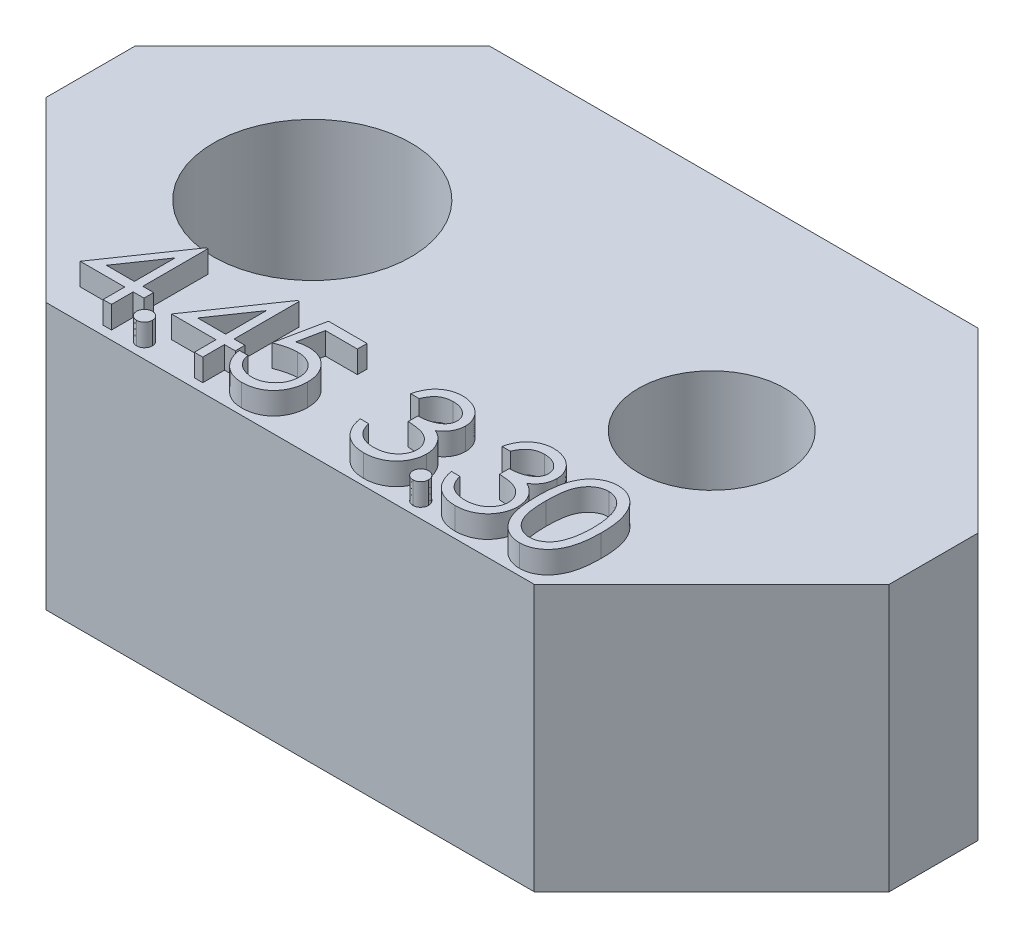
from build123d import *

# Parameters (mm, degrees)
SKETCH_1_R      = 2.225
SKETCH_1_R_2    = 1.65
EXTRUDE_1_DEPTH = 6
SKETCH_1_3_R    = 2.225
SKETCH_1_3_R_2  = 1.65
EXTRUDE_2_DEPTH = 2
EXTRUDE_3_DEPTH = 0.5


with BuildPart() as part:
    # Эскиз1 → Бобышка-Вытянуть1 (new body)
    with BuildSketch(Plane(origin=(0, 0, 0), x_dir=(1, 0, 0), z_dir=(0, 1, 0))):
        Polygon((9.5, 1), (5.5, 5), (-5.5, 5), (-9.5, 1), (-9.5, -1), (-5.5, -5), (5.5, -5), (9.5, -1), align=None)
        with Locations((-4.5, 0)):
            Circle(SKETCH_1_R, mode=Mode.SUBTRACT)
        with Locations((4.5, 0)):
            Circle(SKETCH_1_R_2, mode=Mode.SUBTRACT)
    extrude(amount=EXTRUDE_1_DEPTH)

    # Эскиз1<3> → Бобышка-Вытянуть2 (add)
    with BuildSketch(Plane(origin=(0, 0, 0), x_dir=(1, 0, 0), z_dir=(0, 1, 0))):
        with Locations((-4.5, 0)):
            Circle(SKETCH_1_3_R)
        with Locations((4.5, 0)):
            Circle(SKETCH_1_3_R_2)
    extrude(amount=EXTRUDE_2_DEPTH)

    # Эскиз3 → Бобышка-Вытянуть3 (add)
    # profile 1 of 8: a face of its own
    with BuildSketch(Plane(origin=(0, 6, 0), x_dir=(1, 0, 0), z_dir=(0, 1, 0))):
        Polygon((-4.263157719, -2.629059829), (-4.22457265, -2.629059829), (-4.22457265, -4.094444444), (-3.98034188, -4.094444444), (-3.98034188, -4.311538462), (-4.22457265, -4.311538462), (-4.22457265, -4.8), (-4.414529915, -4.8), (-4.414529915, -4.311538462), (-5.418589744, -4.311538462), align=None)
        Polygon((-4.414529915, -4.094444444), (-4.414529915, -3.175186966), (-5.045459402, -4.094444444), align=None, mode=Mode.SUBTRACT)
    # profile 2 of 8: a face of its own
    with BuildSketch(Plane(origin=(0, 6, 0), x_dir=(1, 0, 0), z_dir=(0, 1, 0))):
        with BuildLine():
            add(Edge.make_bspline(
                [(-3.630277778, -4.474358974), (-3.61849084, -4.475059389), (-3.595383926, -4.476432471), (-3.561977406, -4.48585265), (-3.53174254, -4.502579554), (-3.504811135, -4.524872758), (-3.482612456, -4.551902993), (-3.465289443, -4.581896709), (-3.455951324, -4.61558291), (-3.454588244, -4.638823714), (-3.453888889, -4.650747863)],
                knots=[0, 0, 0, 0, 1.020151414, 1.999887582, 2.974338812, 3.990962822, 5.007586832, 5.987933904, 6.967670073, 8, 8, 8, 8], degree=3))
            add(Edge.make_bspline(
                [(-3.453888889, -4.650747863), (-3.454611943, -4.662385496), (-3.456037794, -4.685334737), (-3.465268038, -4.71876686), (-3.482744478, -4.748779321), (-3.504658021, -4.776176328), (-3.531749198, -4.798516759), (-3.562048886, -4.815101354), (-3.595305504, -4.825196027), (-3.618477757, -4.826481931), (-3.630277778, -4.827136752)],
                knots=[0, 0, 0, 0, 1.009421747, 1.99056486, 2.972319754, 3.999869655, 5.017953583, 5.993804169, 6.978383603, 8, 8, 8, 8], degree=3))
            add(Edge.make_bspline(
                [(-3.630277778, -4.827136752), (-3.642086302, -4.826505624), (-3.665139634, -4.825273498), (-3.698272116, -4.814894086), (-3.72875633, -4.798672279), (-3.755842232, -4.776134672), (-3.777939308, -4.7489203), (-3.794646087, -4.718560166), (-3.804679177, -4.685430439), (-3.80599869, -4.662404346), (-3.806666667, -4.650747863)],
                knots=[0, 0, 0, 0, 1.022052826, 1.995314843, 2.982371812, 4.00089066, 5.028879526, 6.005146991, 6.990147033, 8, 8, 8, 8], degree=3))
            add(Edge.make_bspline(
                [(-3.806666667, -4.650747863), (-3.806024349, -4.638804191), (-3.804770304, -4.615485636), (-3.794625024, -4.582103319), (-3.778068934, -4.551763358), (-3.755689481, -4.524913998), (-3.728762883, -4.502424534), (-3.698345654, -4.486056778), (-3.665059837, -4.476356147), (-3.642072874, -4.475036244), (-3.630277778, -4.474358974)],
                knots=[0, 0, 0, 0, 1.032775665, 2.016367738, 2.991239715, 4.008302682, 5.025365648, 6.011011707, 6.979408107, 8, 8, 8, 8], degree=3))
        make_face()
    # profile 3 of 8: a face of its own
    with BuildSketch(Plane(origin=(0, 6, 0), x_dir=(1, 0, 0), z_dir=(0, 1, 0))):
        Polygon((-2.206191907, -2.629059829), (-2.167606838, -2.629059829), (-2.167606838, -4.094444444), (-1.923376068, -4.094444444), (-1.923376068, -4.311538462), (-2.167606838, -4.311538462), (-2.167606838, -4.8), (-2.357564103, -4.8), (-2.357564103, -4.311538462), (-3.361623932, -4.311538462), align=None)
        Polygon((-2.357564103, -4.094444444), (-2.357564103, -3.175186966), (-2.98849359, -4.094444444), align=None, mode=Mode.SUBTRACT)
    # profile 4 of 8: a face of its own
    with BuildSketch(Plane(origin=(0, 6, 0), x_dir=(1, 0, 0), z_dir=(0, 1, 0))):
        with BuildLine():
            Line((-0.582820513, -2.683333333), (-0.582820513, -2.90042735))
            Line((-0.582820513, -2.90042735), (-1.302792468, -2.90042735))
            Line((-1.302792468, -2.90042735), (-1.416851629, -3.457154781))
            add(Edge.make_bspline(
                [(-1.416851629, -3.457154781), (-1.394441648, -3.450967902), (-1.351025854, -3.438981803), (-1.286945367, -3.425673552), (-1.226111034, -3.417651117), (-1.186634977, -3.416555705), (-1.167532719, -3.416025641)],
                knots=[0, 0, 0, 0, 1.100273476, 2.13160584, 3.095893838, 4, 4, 4, 4], degree=3))
            add(Edge.make_bspline(
                [(-1.167532719, -3.416025641), (-1.143896362, -3.416537231), (-1.097421379, -3.417543144), (-1.029422587, -3.42720231), (-0.964511742, -3.442405973), (-0.902824595, -3.463645526), (-0.844247024, -3.490805222), (-0.789317974, -3.524732329), (-0.737212951, -3.564364391), (-0.688866715, -3.609930184), (-0.645006777, -3.660078019), (-0.606443535, -3.713997303), (-0.573688064, -3.771164032), (-0.547344179, -3.8321244), (-0.526307939, -3.896204459), (-0.512306494, -3.96407845), (-0.502983056, -4.035106598), (-0.501941422, -4.083671743), (-0.501410256, -4.108436832)],
                knots=[0, 0, 0, 0, 1.052922333, 2.070308379, 3.05430497, 4.020497103, 4.973039431, 5.925935799, 6.892292201, 7.88610001, 8.88166317, 9.857072816, 10.836096531, 11.812156883, 12.81219415, 13.836441305, 14.89672472, 16, 16, 16, 16], degree=3))
            add(Edge.make_bspline(
                [(-0.501410256, -4.108436832), (-0.501812469, -4.125685985), (-0.502611457, -4.159951182), (-0.506674603, -4.210838389), (-0.514497632, -4.260648293), (-0.525000969, -4.309387501), (-0.538633765, -4.35696374), (-0.555137145, -4.403513188), (-0.575333791, -4.448746117), (-0.597487051, -4.493090523), (-0.622431349, -4.535543906), (-0.650116447, -4.575245912), (-0.679366053, -4.61279212), (-0.710838701, -4.647779854), (-0.744826922, -4.679979203), (-0.780919092, -4.709581259), (-0.818827213, -4.737086635), (-0.859137764, -4.761378829), (-0.900952504, -4.783732617), (-0.944875283, -4.802071137), (-0.989906278, -4.818466552), (-1.036693607, -4.831535171), (-1.085131294, -4.841775335), (-1.135299182, -4.84873046), (-1.186934158, -4.85379621), (-1.221934761, -4.854113321), (-1.239614717, -4.854273504)],
                knots=[0, 0, 0, 0, 1.056347294, 2.098418968, 3.122841568, 4.141288669, 5.149314143, 6.15115421, 7.162517403, 8.180376062, 9.185164535, 10.17417709, 11.141909838, 12.097768115, 13.052685741, 14.0056014, 14.954263652, 15.917497458, 16.885230207, 17.854509472, 18.828990115, 19.81800267, 20.826176721, 21.857883937, 22.917946725, 24, 24, 24, 24], degree=3))
            add(Edge.make_bspline(
                [(-1.239614717, -4.854273504), (-1.260705293, -4.853855712), (-1.302198509, -4.853033754), (-1.362989519, -4.844434956), (-1.421478828, -4.832119635), (-1.477195604, -4.813591986), (-1.530639177, -4.790376813), (-1.581090059, -4.761036081), (-1.629837362, -4.727786813), (-1.674899403, -4.688549647), (-1.716722386, -4.645662544), (-1.754161084, -4.599121495), (-1.787503771, -4.549694642), (-1.816216504, -4.497141948), (-1.840708164, -4.441601504), (-1.859948657, -4.382865213), (-1.875477948, -4.321239972), (-1.882047731, -4.278813801), (-1.885384615, -4.257264957)],
                knots=[0, 0, 0, 0, 1.0467383, 2.05933395, 3.04377827, 4.011590433, 4.970194871, 5.932262533, 6.905835911, 7.896367577, 8.894135286, 9.877477877, 10.858688626, 11.851381753, 12.8477658, 13.868841284, 14.917554742, 16, 16, 16, 16], degree=3))
            Line((-1.885384615, -4.257264957), (-1.69542735, -4.257264957))
            add(Edge.make_bspline(
                [(-1.69542735, -4.257264957), (-1.690753413, -4.277449764), (-1.681769847, -4.316246084), (-1.662051132, -4.370754086), (-1.637941769, -4.419328092), (-1.609273425, -4.46261065), (-1.575074121, -4.500353234), (-1.536049181, -4.533988314), (-1.492296034, -4.564332321), (-1.443677271, -4.589625137), (-1.392385552, -4.611196241), (-1.338702525, -4.625560361), (-1.284089896, -4.635660425), (-1.247152025, -4.636671442), (-1.228590411, -4.637179487)],
                knots=[0, 0, 0, 0, 1.136247022, 2.183929868, 3.172523383, 4.106158343, 5.02341133, 5.958108904, 6.928429099, 7.938127109, 8.96079061, 9.975095812, 10.982467395, 12, 12, 12, 12], degree=3))
            add(Edge.make_bspline(
                [(-1.228590411, -4.637179487), (-1.210472685, -4.636683112), (-1.174798735, -4.635705745), (-1.122298515, -4.628183104), (-1.071611682, -4.616597335), (-1.023238376, -4.599258899), (-0.976332111, -4.578186141), (-0.932079402, -4.551144166), (-0.889200043, -4.520023108), (-0.849026839, -4.484368384), (-0.812233458, -4.445077187), (-0.779723803, -4.403059907), (-0.752644432, -4.358236861), (-0.72982428, -4.31138405), (-0.712495857, -4.26198797), (-0.70013393, -4.210280116), (-0.692874937, -4.156132771), (-0.691876367, -4.119200379), (-0.691367521, -4.100380609)],
                knots=[0, 0, 0, 0, 1.027316725, 2.022795036, 3.002884548, 3.971462791, 4.93288096, 5.914575861, 6.907176829, 7.935150275, 8.956128384, 9.956726525, 10.942570165, 11.921478529, 12.907843606, 13.90538589, 14.932640048, 16, 16, 16, 16], degree=3))
            add(Edge.make_bspline(
                [(-0.691367521, -4.100380609), (-0.691765745, -4.083401464), (-0.69254521, -4.050167203), (-0.698913698, -4.001544826), (-0.709991105, -3.955538748), (-0.725366499, -3.911926807), (-0.744887916, -3.870667868), (-0.768743543, -3.83171935), (-0.797381074, -3.795594604), (-0.830093787, -3.762276726), (-0.865930793, -3.731527683), (-0.905508675, -3.70531483), (-0.947999203, -3.683262842), (-0.992890437, -3.664232195), (-1.041250161, -3.650564126), (-1.092120696, -3.640302595), (-1.146051371, -3.634366637), (-1.182924121, -3.633543019), (-1.201877671, -3.633119658)],
                knots=[0, 0, 0, 0, 1.045622112, 2.046656509, 3.013763289, 3.955457236, 4.890082067, 5.820317437, 6.762574623, 7.722996705, 8.69280354, 9.665887285, 10.63943826, 11.638615906, 12.663482002, 13.728887084, 14.832589034, 16, 16, 16, 16], degree=3))
            add(Edge.make_bspline(
                [(-1.201877671, -3.633119658), (-1.218284214, -3.633470778), (-1.252159562, -3.63419575), (-1.304122414, -3.639533679), (-1.358727409, -3.648145062), (-1.415765223, -3.659990078), (-1.475407149, -3.675490777), (-1.537527325, -3.694065737), (-1.602256362, -3.716273803), (-1.645870414, -3.733045189), (-1.668290598, -3.741666667)],
                knots=[0, 0, 0, 0, 0.817624296, 1.688186739, 2.600797293, 3.572016777, 4.590301741, 5.671205678, 6.80286297, 8, 8, 8, 8], degree=3))
            Line((-1.668290598, -3.741666667), (-1.451196581, -2.683333333))
            Line((-1.451196581, -2.683333333), (-0.582820513, -2.683333333))
        make_face()
    # profile 5 of 8: a face of its own
    with BuildSketch(Plane(origin=(0, 6, 0), x_dir=(1, 0, 0), z_dir=(0, 1, 0))):
        with BuildLine():
            Line((1.077948718, -3.171794872), (0.887991453, -3.171794872))
            add(Edge.make_bspline(
                [(0.887991453, -3.171794872), (0.893137705, -3.150487608), (0.903198207, -3.108833649), (0.924181978, -3.049320687), (0.947041527, -2.993003128), (0.974491128, -2.940935503), (1.004432137, -2.892071405), (1.038735878, -2.847519125), (1.07581971, -2.806145569), (1.116837656, -2.769428516), (1.159853561, -2.73618008), (1.205473545, -2.707831831), (1.252779771, -2.683445319), (1.302099999, -2.663354989), (1.353581065, -2.648220505), (1.406757551, -2.637239961), (1.461768811, -2.630109144), (1.499111402, -2.629413207), (1.518072917, -2.629059829)],
                knots=[0, 0, 0, 0, 1.162005537, 2.271625781, 3.343758855, 4.383309926, 5.390229558, 6.379919256, 7.361854164, 8.333198761, 9.295911338, 10.242430842, 11.177959212, 12.116337295, 13.062827104, 14.020064771, 14.994644689, 16, 16, 16, 16], degree=3))
            add(Edge.make_bspline(
                [(1.518072917, -2.629059829), (1.545700099, -2.629893935), (1.600351834, -2.631543953), (1.680641867, -2.646611255), (1.75806761, -2.670454073), (1.831781584, -2.703397708), (1.900251779, -2.744030035), (1.961173187, -2.792389662), (2.013720048, -2.847543525), (2.057803791, -2.908462743), (2.092320576, -2.973568693), (2.117772811, -3.040576408), (2.133267828, -3.109326933), (2.135275974, -3.155746811), (2.136282051, -3.179003072)],
                knots=[0, 0, 0, 0, 1.083050992, 2.142477498, 3.193116406, 4.255571735, 5.30263384, 6.308962982, 7.297363603, 8.282367274, 9.249857812, 10.179914175, 11.08814088, 12, 12, 12, 12], degree=3))
            add(Edge.make_bspline(
                [(2.136282051, -3.179003072), (2.135578356, -3.201383371), (2.134201333, -3.245178145), (2.122509044, -3.309114479), (2.102832352, -3.369373923), (2.075575876, -3.426210149), (2.040293129, -3.47926279), (1.997552975, -3.52865121), (1.947053746, -3.574594463), (1.908785055, -3.600913382), (1.8890832, -3.614463141)],
                knots=[0, 0, 0, 0, 1.024540389, 2.004866551, 2.965041327, 3.920577974, 4.882998113, 5.874504559, 6.905732034, 8, 8, 8, 8], degree=3))
            add(Edge.make_bspline(
                [(1.8890832, -3.614463141), (1.911599547, -3.625335654), (1.956210942, -3.646877248), (2.017020072, -3.689123349), (2.072221454, -3.737901235), (2.103006084, -3.775966554), (2.118473558, -3.795092147)],
                knots=[0, 0, 0, 0, 1.015518401, 2.012035669, 3.001164323, 4, 4, 4, 4], degree=3))
            add(Edge.make_bspline(
                [(2.118473558, -3.795092147), (2.12865856, -3.809036597), (2.148861778, -3.836697147), (2.173799458, -3.881169176), (2.196423065, -3.926134124), (2.214052007, -3.972797193), (2.227703822, -4.02061754), (2.23746228, -4.069677275), (2.243524498, -4.12001646), (2.244392665, -4.154072102), (2.24482906, -4.171190572)],
                knots=[0, 0, 0, 0, 1.025084078, 2.033381695, 3.024893161, 4.013698104, 4.991890475, 5.976764909, 6.982997093, 8, 8, 8, 8], degree=3))
            add(Edge.make_bspline(
                [(2.24482906, -4.171190572), (2.243743806, -4.200829784), (2.241578407, -4.259968726), (2.222223562, -4.347341534), (2.192219364, -4.432749338), (2.149609693, -4.514437455), (2.097680295, -4.590867495), (2.035899437, -4.659251739), (1.964969085, -4.718033752), (1.885862812, -4.767146604), (1.800157691, -4.80640649), (1.708490548, -4.833655515), (1.612182182, -4.851402858), (1.546137768, -4.853305964), (1.512560764, -4.854273504)],
                knots=[0, 0, 0, 0, 0.955779014, 1.907060117, 2.875433937, 3.871313158, 4.872415639, 5.851225146, 6.836215519, 7.83643374, 8.849228613, 9.86973379, 10.916971861, 12, 12, 12, 12], degree=3))
            add(Edge.make_bspline(
                [(1.512560764, -4.854273504), (1.489930997, -4.853748442), (1.445403161, -4.852715294), (1.379941616, -4.845652521), (1.317456589, -4.832752947), (1.257863594, -4.815394281), (1.201109691, -4.793385942), (1.147368065, -4.76597892), (1.096308082, -4.733738154), (1.048411574, -4.69628308), (1.003684249, -4.654384365), (0.963314745, -4.607298201), (0.926630013, -4.55589501), (0.894612322, -4.499577733), (0.865803307, -4.439074172), (0.842108157, -4.373609604), (0.821252599, -4.303769267), (0.811556171, -4.255099396), (0.806581197, -4.230128205)],
                knots=[0, 0, 0, 0, 1.048658725, 2.063410685, 3.046034179, 4.001477787, 4.936774919, 5.862367409, 6.792675028, 7.730719943, 8.675894397, 9.627829632, 10.600096036, 11.597688215, 12.626045268, 13.701542398, 14.82072376, 16, 16, 16, 16], degree=3))
            Line((0.806581197, -4.230128205), (0.996538462, -4.230128205))
            add(Edge.make_bspline(
                [(0.996538462, -4.230128205), (1.001487404, -4.246425942), (1.011113528, -4.278126455), (1.027499128, -4.323749878), (1.046167083, -4.365574034), (1.066193506, -4.403905732), (1.087226185, -4.43912247), (1.11076045, -4.470293029), (1.135053218, -4.498786509), (1.153365018, -4.514839679), (1.162327057, -4.522696314)],
                knots=[0, 0, 0, 0, 1.198163088, 2.33053128, 3.407730985, 4.417276592, 5.372219308, 6.28897303, 7.162600585, 8, 8, 8, 8], degree=3))
            add(Edge.make_bspline(
                [(1.162327057, -4.522696314), (1.17417832, -4.531833259), (1.197844263, -4.550078945), (1.23640886, -4.573363263), (1.276967148, -4.59353874), (1.320397928, -4.608950309), (1.365764003, -4.621999656), (1.413798648, -4.630539208), (1.464078079, -4.636398245), (1.49840906, -4.636915275), (1.515952858, -4.637179487)],
                knots=[0, 0, 0, 0, 0.946170439, 1.889420265, 2.845303464, 3.807233317, 4.801018734, 5.828864929, 6.890507805, 8, 8, 8, 8], degree=3))
            add(Edge.make_bspline(
                [(1.515952858, -4.637179487), (1.535760929, -4.636807011), (1.574493901, -4.636078666), (1.631011839, -4.629380501), (1.684779677, -4.619625441), (1.735200446, -4.604559018), (1.78293461, -4.585943932), (1.827313036, -4.562570849), (1.868918301, -4.535148088), (1.907217512, -4.503979169), (1.941655986, -4.469857598), (1.971978454, -4.434168741), (1.997756225, -4.397063072), (2.018550103, -4.358335256), (2.034969722, -4.318145666), (2.046147657, -4.276381516), (2.053919764, -4.233384598), (2.054552715, -4.204157079), (2.054871795, -4.189423077)],
                knots=[0, 0, 0, 0, 1.217147791, 2.380027433, 3.494444702, 4.572153297, 5.609568379, 6.639424714, 7.649109417, 8.668170816, 9.669597737, 10.625200337, 11.543417969, 12.441394052, 13.322311151, 14.205496177, 15.095365482, 16, 16, 16, 16], degree=3))
            add(Edge.make_bspline(
                [(2.054871795, -4.189423077), (2.053946327, -4.169700982), (2.052099996, -4.130354925), (2.038003855, -4.072468583), (2.01481797, -4.016695376), (1.98235888, -3.963986874), (1.94284632, -3.915136686), (1.896663734, -3.871550599), (1.843427615, -3.835585354), (1.794429884, -3.8107365), (1.751029052, -3.793780745), (1.713887367, -3.782486838), (1.672305992, -3.772923341), (1.626787772, -3.76402592), (1.576989731, -3.756453485), (1.522966086, -3.750138673), (1.464705887, -3.745085862), (1.42437361, -3.742829438), (1.403589744, -3.741666667)],
                knots=[0, 0, 0, 0, 1.07054697, 2.135767047, 3.216561865, 4.33974944, 5.486079747, 6.621378074, 7.775625952, 8.963672916, 9.598146892, 10.304877434, 11.070270905, 11.915000392, 12.823868403, 13.805723172, 14.86925407, 16, 16, 16, 16], degree=3))
            Line((1.403589744, -3.741666667), (1.403589744, -3.52457265))
            add(Edge.make_bspline(
                [(1.403589744, -3.52457265), (1.429776639, -3.524128268), (1.481070334, -3.523257834), (1.55599689, -3.512730133), (1.627645036, -3.498167086), (1.694426923, -3.475860327), (1.75529543, -3.449952148), (1.808102999, -3.419803431), (1.852109798, -3.386290701), (1.88710197, -3.348896695), (1.913426789, -3.30879188), (1.932674424, -3.266992759), (1.944044145, -3.223132969), (1.945561896, -3.19320048), (1.946324786, -3.178155048)],
                knots=[0, 0, 0, 0, 1.321986639, 2.589447074, 3.816329219, 5.01088745, 6.139805852, 7.153945165, 8.075214402, 8.924034688, 9.728124013, 10.488707548, 11.240355623, 12, 12, 12, 12], degree=3))
            add(Edge.make_bspline(
                [(1.946324786, -3.178155048), (1.946074166, -3.167101364), (1.94557557, -3.145110584), (1.939287692, -3.112982566), (1.929838868, -3.081836756), (1.916848746, -3.051805604), (1.899461721, -3.023097391), (1.878654291, -2.995467362), (1.853878344, -2.969073267), (1.825487526, -2.94447136), (1.795000387, -2.921025202), (1.761587428, -2.901120288), (1.726256104, -2.884099227), (1.688967298, -2.870063004), (1.649600001, -2.859504292), (1.608339178, -2.851923093), (1.565106151, -2.847183178), (1.535610865, -2.846500755), (1.520616987, -2.846153846)],
                knots=[0, 0, 0, 0, 0.884392785, 1.759457502, 2.611959086, 3.489218968, 4.37281399, 5.2945488, 6.255912374, 7.266815255, 8.301784654, 9.332968512, 10.37626691, 11.440494194, 12.520033166, 13.637162961, 14.798855837, 16, 16, 16, 16], degree=3))
            add(Edge.make_bspline(
                [(1.520616987, -2.846153846), (1.496516217, -2.846995289), (1.449441806, -2.848638822), (1.381578499, -2.863033978), (1.31849014, -2.886001676), (1.270267232, -2.913417359), (1.234657294, -2.940480717), (1.209210765, -2.964116255), (1.184221695, -2.990382773), (1.161334071, -3.020898076), (1.138187428, -3.053595611), (1.117114765, -3.090137551), (1.096637713, -3.129570685), (1.084299028, -3.157447569), (1.077948718, -3.171794872)],
                knots=[0, 0, 0, 0, 1.472543308, 2.876219568, 4.221790263, 5.565193594, 6.249813518, 6.953379497, 7.687249741, 8.463570142, 9.283606569, 10.136032583, 11.040678096, 12, 12, 12, 12], degree=3))
        make_face()
    # profile 6 of 8: a face of its own
    with BuildSketch(Plane(origin=(0, 6, 0), x_dir=(1, 0, 0), z_dir=(0, 1, 0))):
        with BuildLine():
            add(Edge.make_bspline(
                [(2.594893162, -4.474358974), (2.6066801, -4.475059389), (2.629787014, -4.476432471), (2.663193534, -4.48585265), (2.6934284, -4.502579554), (2.720359805, -4.524872758), (2.742558484, -4.551902993), (2.759881497, -4.581896709), (2.769219616, -4.61558291), (2.770582696, -4.638823714), (2.771282051, -4.650747863)],
                knots=[0, 0, 0, 0, 1.020151414, 1.999887582, 2.974338812, 3.990962822, 5.007586832, 5.987933904, 6.967670073, 8, 8, 8, 8], degree=3))
            add(Edge.make_bspline(
                [(2.771282051, -4.650747863), (2.770558997, -4.662385496), (2.769133146, -4.685334737), (2.759902902, -4.71876686), (2.742426462, -4.748779321), (2.720512919, -4.776176328), (2.693421742, -4.798516759), (2.663122054, -4.815101354), (2.629865436, -4.825196027), (2.606693184, -4.826481931), (2.594893162, -4.827136752)],
                knots=[0, 0, 0, 0, 1.009421747, 1.99056486, 2.972319754, 3.999869655, 5.017953583, 5.993804169, 6.978383603, 8, 8, 8, 8], degree=3))
            add(Edge.make_bspline(
                [(2.594893162, -4.827136752), (2.583084638, -4.826505624), (2.560031307, -4.825273498), (2.526898824, -4.814894086), (2.49641461, -4.798672279), (2.469328708, -4.776134672), (2.447231633, -4.7489203), (2.430524853, -4.718560166), (2.420491763, -4.685430439), (2.41917225, -4.662404346), (2.418504274, -4.650747863)],
                knots=[0, 0, 0, 0, 1.022052826, 1.995314843, 2.982371812, 4.00089066, 5.028879526, 6.005146991, 6.990147033, 8, 8, 8, 8], degree=3))
            add(Edge.make_bspline(
                [(2.418504274, -4.650747863), (2.419146591, -4.638804191), (2.420400636, -4.615485636), (2.430545916, -4.582103319), (2.447102006, -4.551763358), (2.46948146, -4.524913998), (2.496408058, -4.502424534), (2.526825286, -4.486056778), (2.560111104, -4.476356147), (2.583098066, -4.475036244), (2.594893162, -4.474358974)],
                knots=[0, 0, 0, 0, 1.032775665, 2.016367738, 2.991239715, 4.008302682, 5.025365648, 6.011011707, 6.979408107, 8, 8, 8, 8], degree=3))
        make_face()
    # profile 7 of 8: a face of its own
    with BuildSketch(Plane(origin=(0, 6, 0), x_dir=(1, 0, 0), z_dir=(0, 1, 0))):
        with BuildLine():
            Line((3.13491453, -3.171794872), (2.944957265, -3.171794872))
            add(Edge.make_bspline(
                [(2.944957265, -3.171794872), (2.950103517, -3.150487608), (2.960164019, -3.108833649), (2.98114779, -3.049320687), (3.004007339, -2.993003128), (3.03145694, -2.940935503), (3.061397949, -2.892071405), (3.09570169, -2.847519125), (3.132785522, -2.806145569), (3.173803468, -2.769428516), (3.216819373, -2.73618008), (3.262439357, -2.707831831), (3.309745583, -2.683445319), (3.359065811, -2.663354989), (3.410546877, -2.648220505), (3.463723363, -2.637239961), (3.518734623, -2.630109144), (3.556077214, -2.629413207), (3.575038729, -2.629059829)],
                knots=[0, 0, 0, 0, 1.162005537, 2.271625781, 3.343758855, 4.383309926, 5.390229558, 6.379919256, 7.361854164, 8.333198761, 9.295911338, 10.242430842, 11.177959212, 12.116337295, 13.062827104, 14.020064771, 14.994644689, 16, 16, 16, 16], degree=3))
            add(Edge.make_bspline(
                [(3.575038729, -2.629059829), (3.602665911, -2.629893935), (3.657317646, -2.631543953), (3.737607679, -2.646611255), (3.815033422, -2.670454073), (3.888747396, -2.703397708), (3.957217591, -2.744030035), (4.018138999, -2.792389662), (4.07068586, -2.847543525), (4.114769603, -2.908462743), (4.149286388, -2.973568693), (4.174738623, -3.040576408), (4.19023364, -3.109326933), (4.192241786, -3.155746811), (4.193247863, -3.179003072)],
                knots=[0, 0, 0, 0, 1.083050992, 2.142477498, 3.193116406, 4.255571735, 5.30263384, 6.308962982, 7.297363603, 8.282367274, 9.249857812, 10.179914175, 11.08814088, 12, 12, 12, 12], degree=3))
            add(Edge.make_bspline(
                [(4.193247863, -3.179003072), (4.192544168, -3.201383371), (4.191167145, -3.245178145), (4.179474856, -3.309114479), (4.159798164, -3.369373923), (4.132541688, -3.426210149), (4.097258941, -3.47926279), (4.054518787, -3.52865121), (4.004019558, -3.574594463), (3.965750867, -3.600913382), (3.946049012, -3.614463141)],
                knots=[0, 0, 0, 0, 1.024540389, 2.004866551, 2.965041327, 3.920577974, 4.882998113, 5.874504559, 6.905732034, 8, 8, 8, 8], degree=3))
            add(Edge.make_bspline(
                [(3.946049012, -3.614463141), (3.968565359, -3.625335654), (4.013176754, -3.646877248), (4.073985884, -3.689123349), (4.129187265, -3.737901235), (4.159971896, -3.775966554), (4.17543937, -3.795092147)],
                knots=[0, 0, 0, 0, 1.015518401, 2.012035669, 3.001164323, 4, 4, 4, 4], degree=3))
            add(Edge.make_bspline(
                [(4.17543937, -3.795092147), (4.185624372, -3.809036597), (4.20582759, -3.836697147), (4.23076527, -3.881169176), (4.253388877, -3.926134124), (4.271017819, -3.972797193), (4.284669634, -4.02061754), (4.294428092, -4.069677275), (4.30049031, -4.12001646), (4.301358477, -4.154072102), (4.301794872, -4.171190572)],
                knots=[0, 0, 0, 0, 1.025084078, 2.033381695, 3.024893161, 4.013698104, 4.991890475, 5.976764909, 6.982997093, 8, 8, 8, 8], degree=3))
            add(Edge.make_bspline(
                [(4.301794872, -4.171190572), (4.300709618, -4.200829784), (4.298544219, -4.259968726), (4.279189374, -4.347341534), (4.249185176, -4.432749338), (4.206575505, -4.514437455), (4.154646107, -4.590867495), (4.092865249, -4.659251739), (4.021934897, -4.718033752), (3.942828624, -4.767146604), (3.857123503, -4.80640649), (3.76545636, -4.833655515), (3.669147994, -4.851402858), (3.60310358, -4.853305964), (3.569526576, -4.854273504)],
                knots=[0, 0, 0, 0, 0.955779014, 1.907060117, 2.875433937, 3.871313158, 4.872415639, 5.851225146, 6.836215519, 7.83643374, 8.849228613, 9.86973379, 10.916971861, 12, 12, 12, 12], degree=3))
            add(Edge.make_bspline(
                [(3.569526576, -4.854273504), (3.546896809, -4.853748442), (3.502368973, -4.852715294), (3.436907428, -4.845652521), (3.374422401, -4.832752947), (3.314829406, -4.815394281), (3.258075503, -4.793385942), (3.204333877, -4.76597892), (3.153273894, -4.733738154), (3.105377386, -4.69628308), (3.060650061, -4.654384365), (3.020280557, -4.607298201), (2.983595825, -4.55589501), (2.951578134, -4.499577733), (2.922769119, -4.439074172), (2.899073969, -4.373609604), (2.878218411, -4.303769267), (2.868521983, -4.255099396), (2.863547009, -4.230128205)],
                knots=[0, 0, 0, 0, 1.048658725, 2.063410685, 3.046034179, 4.001477787, 4.936774919, 5.862367409, 6.792675028, 7.730719943, 8.675894397, 9.627829632, 10.600096036, 11.597688215, 12.626045268, 13.701542398, 14.82072376, 16, 16, 16, 16], degree=3))
            Line((2.863547009, -4.230128205), (3.053504274, -4.230128205))
            add(Edge.make_bspline(
                [(3.053504274, -4.230128205), (3.058453216, -4.246425942), (3.06807934, -4.278126455), (3.08446494, -4.323749878), (3.103132895, -4.365574034), (3.123159318, -4.403905732), (3.144191997, -4.43912247), (3.167726262, -4.470293029), (3.19201903, -4.498786509), (3.21033083, -4.514839679), (3.219292869, -4.522696314)],
                knots=[0, 0, 0, 0, 1.198163088, 2.33053128, 3.407730985, 4.417276592, 5.372219308, 6.28897303, 7.162600585, 8, 8, 8, 8], degree=3))
            add(Edge.make_bspline(
                [(3.219292869, -4.522696314), (3.231144132, -4.531833259), (3.254810075, -4.550078945), (3.293374672, -4.573363263), (3.33393296, -4.59353874), (3.37736374, -4.608950309), (3.422729815, -4.621999656), (3.47076446, -4.630539208), (3.521043891, -4.636398245), (3.555374872, -4.636915275), (3.57291867, -4.637179487)],
                knots=[0, 0, 0, 0, 0.946170439, 1.889420265, 2.845303464, 3.807233317, 4.801018734, 5.828864929, 6.890507805, 8, 8, 8, 8], degree=3))
            add(Edge.make_bspline(
                [(3.57291867, -4.637179487), (3.592726741, -4.636807011), (3.631459713, -4.636078666), (3.687977651, -4.629380501), (3.741745489, -4.619625441), (3.792166258, -4.604559018), (3.839900422, -4.585943932), (3.884278848, -4.562570849), (3.925884113, -4.535148088), (3.964183324, -4.503979169), (3.998621798, -4.469857598), (4.028944266, -4.434168741), (4.054722037, -4.397063072), (4.075515915, -4.358335256), (4.091935534, -4.318145666), (4.103113469, -4.276381516), (4.110885576, -4.233384598), (4.111518527, -4.204157079), (4.111837607, -4.189423077)],
                knots=[0, 0, 0, 0, 1.217147791, 2.380027433, 3.494444702, 4.572153297, 5.609568379, 6.639424714, 7.649109417, 8.668170816, 9.669597737, 10.625200337, 11.543417969, 12.441394052, 13.322311151, 14.205496177, 15.095365482, 16, 16, 16, 16], degree=3))
            add(Edge.make_bspline(
                [(4.111837607, -4.189423077), (4.110912139, -4.169700982), (4.109065808, -4.130354925), (4.094969667, -4.072468583), (4.071783782, -4.016695376), (4.039324692, -3.963986874), (3.999812132, -3.915136686), (3.953629546, -3.871550599), (3.900393427, -3.835585354), (3.851395696, -3.8107365), (3.807994864, -3.793780745), (3.770853179, -3.782486838), (3.729271804, -3.772923341), (3.683753584, -3.76402592), (3.633955543, -3.756453485), (3.579931898, -3.750138673), (3.521671699, -3.745085862), (3.481339422, -3.742829438), (3.460555556, -3.741666667)],
                knots=[0, 0, 0, 0, 1.07054697, 2.135767047, 3.216561865, 4.33974944, 5.486079747, 6.621378074, 7.775625952, 8.963672916, 9.598146892, 10.304877434, 11.070270905, 11.915000392, 12.823868403, 13.805723172, 14.86925407, 16, 16, 16, 16], degree=3))
            Line((3.460555556, -3.741666667), (3.460555556, -3.52457265))
            add(Edge.make_bspline(
                [(3.460555556, -3.52457265), (3.486742451, -3.524128268), (3.538036146, -3.523257834), (3.612962702, -3.512730133), (3.684610848, -3.498167086), (3.751392735, -3.475860327), (3.812261242, -3.449952148), (3.865068811, -3.419803431), (3.90907561, -3.386290701), (3.944067782, -3.348896695), (3.970392601, -3.30879188), (3.989640236, -3.266992759), (4.001009957, -3.223132969), (4.002527708, -3.19320048), (4.003290598, -3.178155048)],
                knots=[0, 0, 0, 0, 1.321986639, 2.589447074, 3.816329219, 5.01088745, 6.139805852, 7.153945165, 8.075214402, 8.924034688, 9.728124013, 10.488707548, 11.240355623, 12, 12, 12, 12], degree=3))
            add(Edge.make_bspline(
                [(4.003290598, -3.178155048), (4.003039978, -3.167101364), (4.002541382, -3.145110584), (3.996253504, -3.112982566), (3.986804679, -3.081836756), (3.973814557, -3.051805604), (3.956427533, -3.023097391), (3.935620103, -2.995467362), (3.910844156, -2.969073267), (3.882453338, -2.94447136), (3.851966199, -2.921025202), (3.81855324, -2.901120288), (3.783221916, -2.884099227), (3.74593311, -2.870063004), (3.706565813, -2.859504292), (3.66530499, -2.851923093), (3.622071963, -2.847183178), (3.592576677, -2.846500755), (3.577582799, -2.846153846)],
                knots=[0, 0, 0, 0, 0.884392785, 1.759457502, 2.611959086, 3.489218968, 4.37281399, 5.2945488, 6.255912374, 7.266815255, 8.301784654, 9.332968512, 10.37626691, 11.440494194, 12.520033166, 13.637162961, 14.798855837, 16, 16, 16, 16], degree=3))
            add(Edge.make_bspline(
                [(3.577582799, -2.846153846), (3.553482028, -2.846995289), (3.506407618, -2.848638822), (3.438544311, -2.863033978), (3.375455952, -2.886001676), (3.327233044, -2.913417359), (3.291623106, -2.940480717), (3.266176577, -2.964116255), (3.241187507, -2.990382773), (3.218299883, -3.020898076), (3.19515324, -3.053595611), (3.174080576, -3.090137551), (3.153603524, -3.129570685), (3.14126484, -3.157447569), (3.13491453, -3.171794872)],
                knots=[0, 0, 0, 0, 1.472543308, 2.876219568, 4.221790263, 5.565193594, 6.249813518, 6.953379497, 7.687249741, 8.463570142, 9.283606569, 10.136032583, 11.040678096, 12, 12, 12, 12], degree=3))
        make_face()
    # profile 8 of 8: a face of its own
    with BuildSketch(Plane(origin=(0, 6, 0), x_dir=(1, 0, 0), z_dir=(0, 1, 0))):
        with BuildLine():
            add(Edge.make_bspline(
                [(4.312649573, -3.74251469), (4.312847946, -3.708589127), (4.313233288, -3.642688232), (4.317520095, -3.546661329), (4.324641373, -3.456575821), (4.334400641, -3.372427396), (4.346276944, -3.294194328), (4.362131071, -3.22208569), (4.380160719, -3.155767737), (4.401056722, -3.095024212), (4.424635051, -3.039036744), (4.450297676, -2.986770075), (4.479063051, -2.938303287), (4.509287184, -2.892862814), (4.542193532, -2.851192484), (4.576845658, -2.812703827), (4.614596031, -2.778286373), (4.654161374, -2.746931704), (4.695899902, -2.719445595), (4.738621896, -2.69523532), (4.782621412, -2.674552543), (4.82801858, -2.658290232), (4.874405365, -2.644857958), (4.921943924, -2.635672261), (4.970712749, -2.629892607), (5.003630807, -2.629340055), (5.020325187, -2.629059829)],
                knots=[0, 0, 0, 0, 1.646270934, 3.197905019, 4.663502075, 6.030701355, 7.308322542, 8.50163776, 9.611534131, 10.641858119, 11.616356847, 12.558055219, 13.465016945, 14.349605745, 15.204443733, 16.039544428, 16.859896111, 17.680448484, 18.487036065, 19.28249412, 20.06191084, 20.843045899, 21.620316918, 22.403196591, 23.190181807, 24, 24, 24, 24], degree=3))
            add(Edge.make_bspline(
                [(5.020325187, -2.629059829), (5.037159024, -2.629354841), (5.070636229, -2.629941527), (5.120130171, -2.635580292), (5.168480692, -2.644936638), (5.215481662, -2.658193609), (5.261519154, -2.674640518), (5.306233076, -2.695255108), (5.349901169, -2.719251375), (5.391829485, -2.74744772), (5.432478324, -2.77888462), (5.470849235, -2.814422044), (5.506945711, -2.85370116), (5.541220777, -2.896301716), (5.572702019, -2.943040791), (5.602682142, -2.993105467), (5.629516659, -3.047371275), (5.655360963, -3.104932796), (5.677668807, -3.167382723), (5.697786965, -3.234369031), (5.714042341, -3.306682944), (5.72758252, -3.383945054), (5.738072052, -3.466439104), (5.745711793, -3.553988256), (5.749747421, -3.646650112), (5.750507426, -3.710003668), (5.750897436, -3.74251469)],
                knots=[0, 0, 0, 0, 0.810914788, 1.612654377, 2.396697861, 3.181598691, 3.963628158, 4.749916497, 5.551656086, 6.361998678, 7.18212741, 8.025565596, 8.878627764, 9.750805457, 10.657531673, 11.591944965, 12.560506719, 13.57287815, 14.630710178, 15.753379473, 16.941251878, 18.199788006, 19.531962791, 20.947069417, 22.433333509, 24, 24, 24, 24], degree=3))
            add(Edge.make_bspline(
                [(5.750897436, -3.74251469), (5.750503382, -3.774883911), (5.749735585, -3.837954017), (5.745757034, -3.93019894), (5.737920147, -4.017283471), (5.728116964, -4.099416465), (5.714539477, -4.176256072), (5.697844924, -4.248068191), (5.679308776, -4.315162939), (5.656427734, -4.376990659), (5.631384114, -4.434413844), (5.604136448, -4.488036357), (5.574944696, -4.538332163), (5.543141026, -4.584898676), (5.509242057, -4.628065769), (5.472522252, -4.667071474), (5.434016708, -4.702855642), (5.393248247, -4.734697341), (5.350666023, -4.762567675), (5.307147914, -4.787492242), (5.261921773, -4.80759011), (5.216012511, -4.824847015), (5.168763451, -4.838031098), (5.120233491, -4.847147192), (5.070669482, -4.853540643), (5.037164726, -4.854028371), (5.020325187, -4.854273504)],
                knots=[0, 0, 0, 0, 1.561518951, 3.042555995, 4.452378317, 5.7783523, 7.031515105, 8.214008947, 9.334062868, 10.386615937, 11.391082383, 12.354592575, 13.286541444, 14.194233754, 15.072674879, 15.931287219, 16.775624067, 17.606195743, 18.42308326, 19.229000347, 20.022332153, 20.807536673, 21.593273796, 22.3848459, 23.188221202, 24, 24, 24, 24], degree=3))
            add(Edge.make_bspline(
                [(5.020325187, -4.854273504), (5.00363127, -4.85399147), (4.970714125, -4.853435354), (4.921938611, -4.847681812), (4.874596371, -4.838431674), (4.828453792, -4.825479728), (4.783274137, -4.809625994), (4.73967305, -4.788971147), (4.697165736, -4.7651834), (4.655865605, -4.738092836), (4.616548726, -4.707055437), (4.578993855, -4.672726558), (4.544144439, -4.634249542), (4.511708581, -4.592231941), (4.480881395, -4.547060314), (4.452524488, -4.498117917), (4.426295448, -4.445598814), (4.402320575, -4.389163697), (4.381064002, -4.32798905), (4.362287531, -4.261375023), (4.347462302, -4.188733662), (4.33477261, -4.110648397), (4.324537388, -4.026783687), (4.317549772, -3.937094002), (4.313230977, -3.841635233), (4.312846911, -3.776157798), (4.312649573, -3.74251469)],
                knots=[0, 0, 0, 0, 0.810891512, 1.598919785, 2.382837074, 3.152667961, 3.926044502, 4.706494248, 5.493654104, 6.291793342, 7.103789334, 7.925228297, 8.761435821, 9.622817696, 10.50288917, 11.416980706, 12.369136599, 13.353924996, 14.394355917, 15.514179734, 16.714354668, 17.994756427, 19.357759367, 20.818452758, 22.365282078, 24, 24, 24, 24], degree=3))
        make_face()
        with BuildLine():
            add(Edge.make_bspline(
                [(4.502606838, -3.741666667), (4.502679075, -3.769938499), (4.502819273, -3.824808574), (4.506481832, -3.904542355), (4.511471258, -3.978910125), (4.517906709, -4.048006312), (4.52746373, -4.111597034), (4.538172121, -4.170119651), (4.551203585, -4.223264457), (4.566622, -4.271396133), (4.58418374, -4.315331522), (4.603358238, -4.356214161), (4.623956866, -4.394526999), (4.647009876, -4.429925896), (4.672116605, -4.46252629), (4.698709957, -4.492905194), (4.727782424, -4.519996701), (4.768001354, -4.552488656), (4.821097318, -4.586064514), (4.887996355, -4.615302387), (4.956738704, -4.633676539), (5.003396841, -4.636013192), (5.026685363, -4.637179487)],
                knots=[0, 0, 0, 0, 1.459021318, 2.831673884, 4.118529203, 5.306027144, 6.411944654, 7.436330062, 8.375795394, 9.233974572, 10.042671642, 10.816086306, 11.563610507, 12.285937304, 12.993564865, 13.685989202, 14.367179055, 15.041617293, 16.353048772, 17.594441528, 18.799311195, 20, 20, 20, 20], degree=3))
            add(Edge.make_bspline(
                [(5.026685363, -4.637179487), (5.050124527, -4.63621321), (5.09695446, -4.634282651), (5.16537347, -4.615656748), (5.231794633, -4.587553741), (5.283847663, -4.554323583), (5.323449011, -4.522677403), (5.351822619, -4.495696163), (5.377864906, -4.465484758), (5.402564637, -4.432888517), (5.425218459, -4.397284681), (5.445818547, -4.358844457), (5.464616571, -4.317461097), (5.475326328, -4.288571779), (5.48080195, -4.273801416)],
                knots=[0, 0, 0, 0, 1.353760809, 2.704726607, 4.075137775, 5.516104923, 6.260822281, 7.007110065, 7.778089737, 8.566572457, 9.372053459, 10.217411131, 11.088608312, 12, 12, 12, 12], degree=3))
            add(Edge.make_bspline(
                [(5.48080195, -4.273801416), (5.487183257, -4.254914859), (5.500140047, -4.216567049), (5.516838596, -4.157080459), (5.529989385, -4.094667359), (5.541820564, -4.029700741), (5.549895983, -3.961701493), (5.556395851, -3.890880014), (5.56022441, -3.817182904), (5.560698997, -3.767111648), (5.560940171, -3.741666667)],
                knots=[0, 0, 0, 0, 0.884706709, 1.796334032, 2.740027952, 3.714592787, 4.726048262, 5.777819803, 6.87074269, 8, 8, 8, 8], degree=3))
            add(Edge.make_bspline(
                [(5.560940171, -3.741666667), (5.560607437, -3.716225801), (5.55995654, -3.66645803), (5.557468557, -3.593573226), (5.551043823, -3.524347485), (5.543908166, -3.45848258), (5.533386989, -3.396343111), (5.522042982, -3.337408879), (5.506802249, -3.282410002), (5.490522195, -3.230485398), (5.471889241, -3.182225002), (5.451378297, -3.137403807), (5.429472757, -3.095805426), (5.405680069, -3.05754399), (5.38028268, -3.022448119), (5.352610257, -2.991221483), (5.32376047, -2.962896269), (5.283351981, -2.930564144), (5.230450863, -2.897597547), (5.164625162, -2.867259207), (5.096123392, -2.849837049), (5.049814684, -2.847380695), (5.026685363, -2.846153846)],
                knots=[0, 0, 0, 0, 1.31362396, 2.569729283, 3.763502607, 4.902122613, 5.988968491, 7.01645872, 7.998833611, 8.933434873, 9.825090667, 10.667526885, 11.477055099, 12.250526234, 12.991942729, 13.710640831, 14.402115721, 15.076753259, 16.378508321, 17.609869233, 18.806226677, 20, 20, 20, 20], degree=3))
            add(Edge.make_bspline(
                [(5.026685363, -2.846153846), (5.003274672, -2.847382388), (4.95641064, -2.849841709), (4.887196877, -2.867194296), (4.820851865, -2.897440232), (4.768090637, -2.930673334), (4.727653966, -2.96232555), (4.699180147, -2.989773549), (4.672482224, -3.019797712), (4.647887948, -3.052697918), (4.624853, -3.088055545), (4.603697817, -3.12614875), (4.584637336, -3.167170575), (4.567048117, -3.211086229), (4.551582669, -3.259213753), (4.538825843, -3.312293096), (4.527040816, -3.370629574), (4.518697963, -3.434564705), (4.511281311, -3.503678197), (4.506514972, -3.578231623), (4.502807021, -3.658099129), (4.502674902, -3.713252906), (4.502606838, -3.741666667)],
                knots=[0, 0, 0, 0, 1.207732386, 2.417664972, 3.655092373, 4.956220595, 5.625982001, 6.301752483, 6.994047911, 7.697131622, 8.419323945, 9.170223765, 9.943494443, 10.752040957, 11.610060368, 12.549350801, 13.567764191, 14.679664412, 15.874934091, 17.154273443, 18.533957287, 20, 20, 20, 20], degree=3))
        make_face(mode=Mode.SUBTRACT)
    extrude(amount=EXTRUDE_3_DEPTH)


solid = part.part
